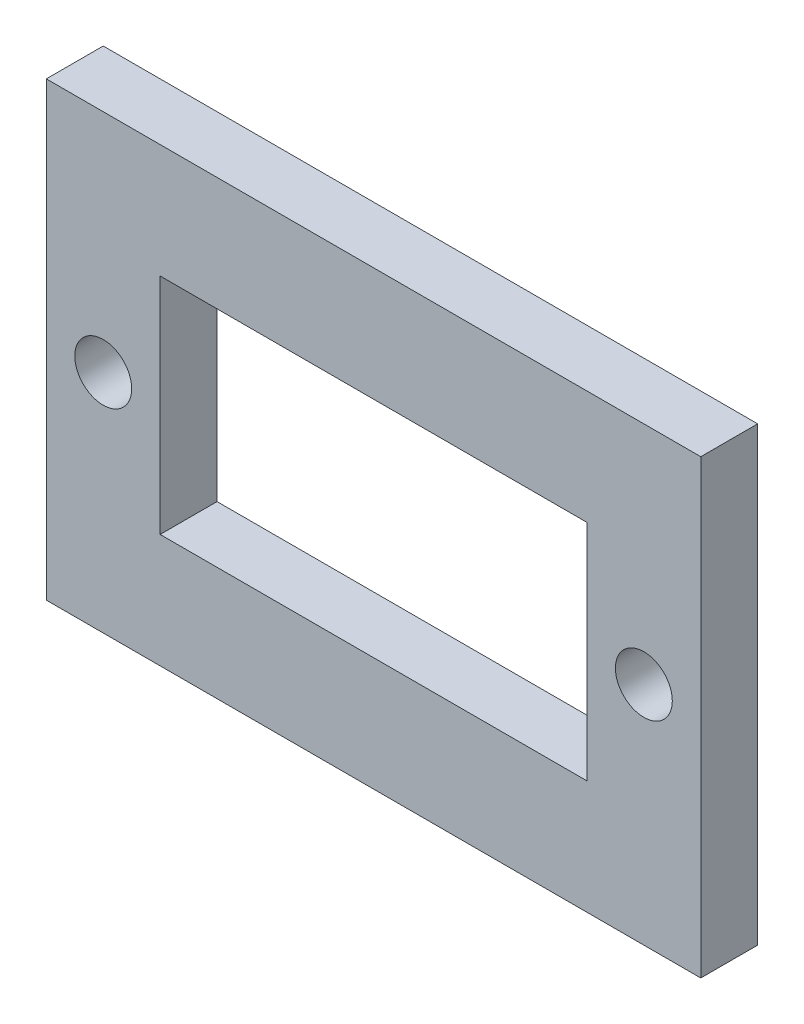
from build123d import *

# Parameters (mm, degrees)
SKETCH1_W           = 34.5
SKETCH1_H           = 23.8
SKETCH1_R           = 1.5
SKETCH1_W_2         = 22.5
SKETCH1_H_2         = 11.8
BOSS_EXTRUDE1_DEPTH = 3


with BuildPart() as part:
    # Sketch1 → Boss-Extrude1 (new body)
    with BuildSketch(Plane.XY):
        with Locations((11.25, 5.9)):
            Rectangle(SKETCH1_W, SKETCH1_H)
        with Locations((-3, 5.9)):
            Circle(SKETCH1_R, mode=Mode.SUBTRACT)
        with Locations((25.5, 5.9)):
            Circle(SKETCH1_R, mode=Mode.SUBTRACT)
        with Locations((11.25, 5.9)):
            Rectangle(SKETCH1_W_2, SKETCH1_H_2, mode=Mode.SUBTRACT)
    extrude(amount=BOSS_EXTRUDE1_DEPTH)


solid = part.part
